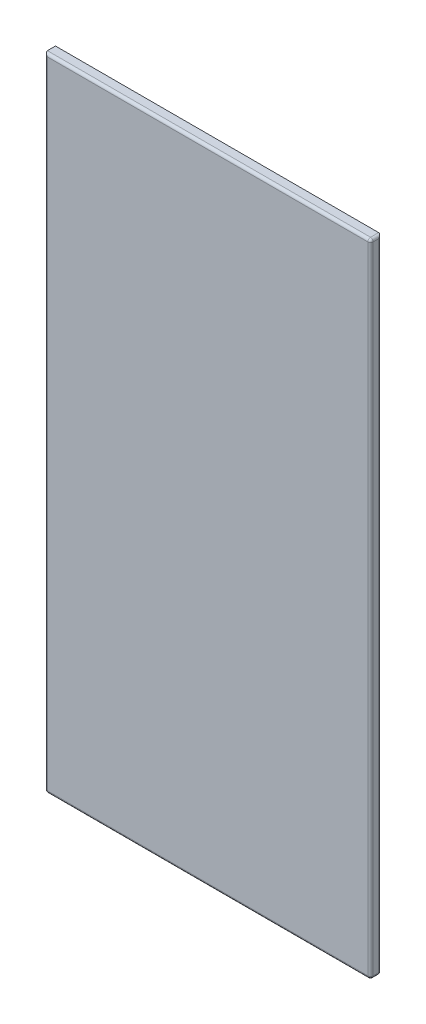
from build123d import *

# Parameters (mm, degrees)
SKETCH1_W           = 605
SKETCH1_H           = 1190
BOSS_EXTRUDE1_DEPTH = 20
FILLET1_R           = 5


with BuildPart() as part:
    # Sketch1 → Boss-Extrude1 (new body)
    with BuildSketch(Plane.XY):
        Rectangle(SKETCH1_W, SKETCH1_H)
    extrude(amount=BOSS_EXTRUDE1_DEPTH)

    # Fillet1
    fillet1_edges = [part.edges().sort_by_distance(p)[0] for p in [
        (-302.5, 0, 20),
        (0, -595, 20),
        (302.5, 0, 20),
        (0, -595, 0),
        (302.5, 0, 0),
        (302.5, -595, 10),
        (-302.5, -595, 10),
        (302.5, 595, 10),
        (0, 595, 20),
    ]]
    fillet(fillet1_edges, radius=FILLET1_R)


solid = part.part
